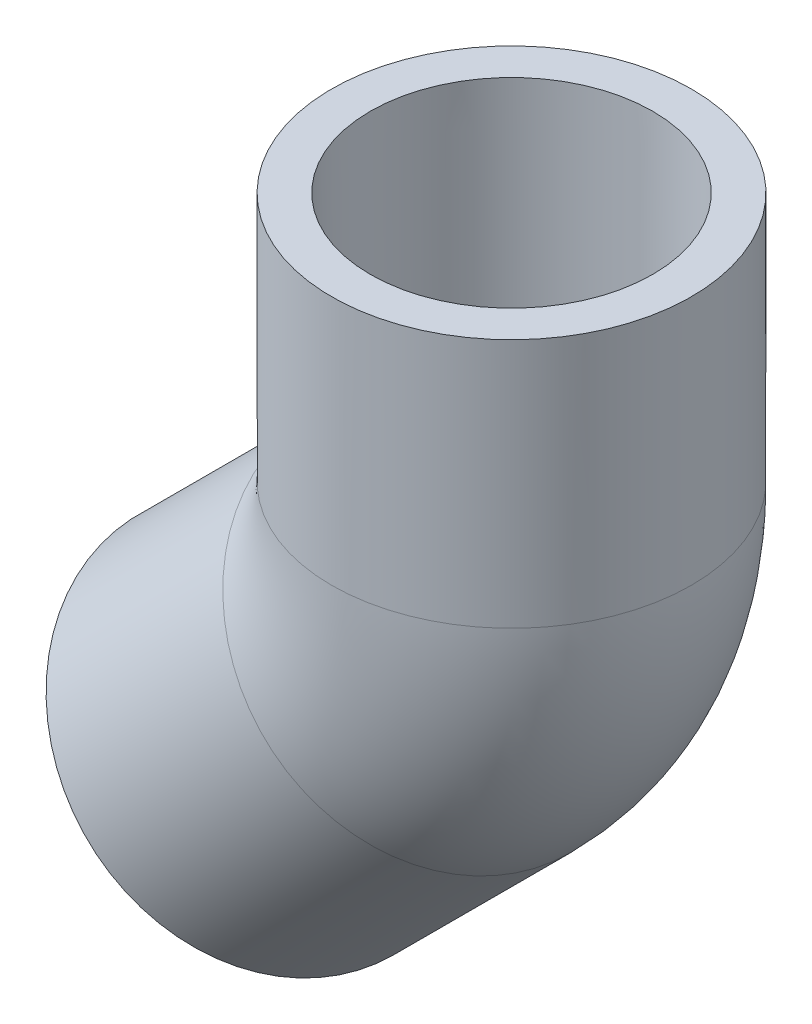
from build123d import *

# Parameters (mm, degrees)
SKETCH3_R   = 13.716
SKETCH3_R_2 = 7.8994


with BuildPart() as part:
    # Sketch1 → Revolve1 (revolve)
    with BuildSketch(Plane.XY):
        Polygon((-8.980256121, -28.377609343), (4.490128061, -14.907225161), (2.298945567, -12.716042667), (-11.063675541, -26.294189922), align=None)
    revolve(axis=Axis((-18.678932732, -18.678932732, 0), (0.707106781, 0.707106781, 0)))



with BuildPart() as body_2:
    # Sketch2 → Revolve2 (revolve)
    with BuildSketch(Plane.XY):
        Polygon((10.7696, 26.416), (10.6172, 7.366), (13.716, 7.366), (13.716, 26.416), align=None)
    revolve(axis=Axis((0, 0, 0), (0, 1, 0)))


with BuildPart() as part_1:
    add(part.part)

    add(body_2.part)  # Sweep1 merges body 2
    # Sweep1: sweep along a path in Sketch4
    with BuildLine(Plane.XY) as sweep1_path:
        ThreePointArc((-5.20854855, -5.20854855), (-1.353657665, 0.560703364), (0, 7.366))
    # Sketch3 → Sweep1 (sweep)
    with BuildSketch(Plane(origin=(-5.20854855, -5.20854855, 0), x_dir=(0, 0, -1), z_dir=(0.707106781, 0.707106781, 0))):
        Circle(SKETCH3_R)
        Circle(SKETCH3_R_2, mode=Mode.SUBTRACT)
    sweep(path=sweep1_path.line)


solid = part_1.part
